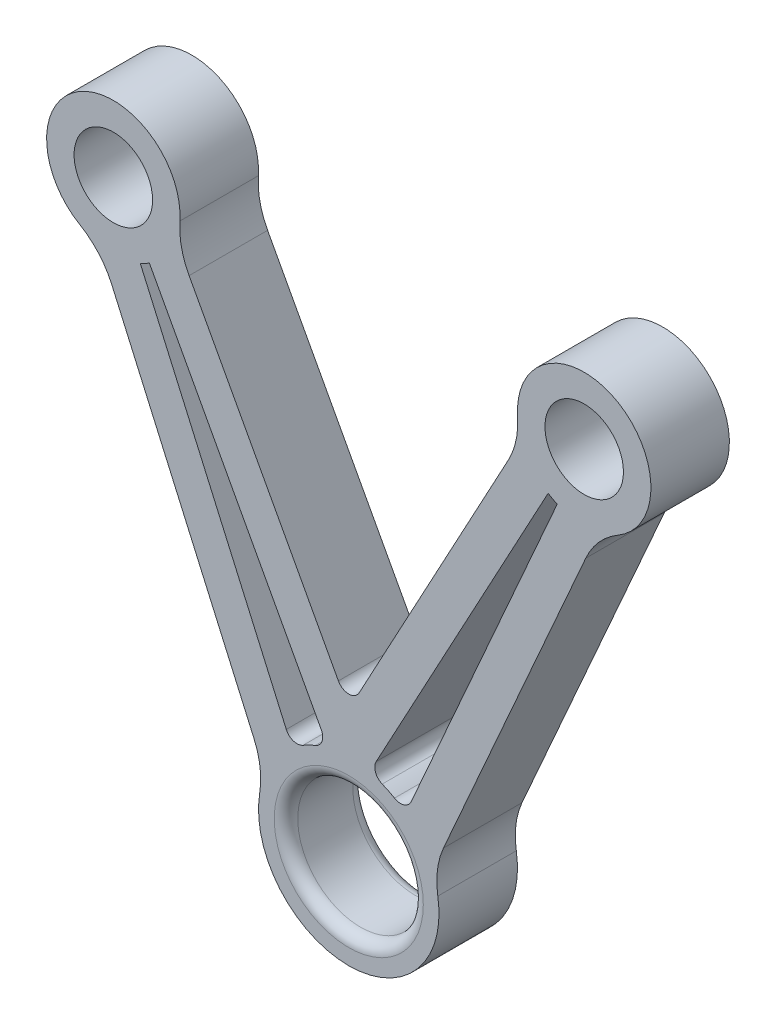
from build123d import *

# Parameters (mm, degrees)
SCHIZZO1_R                   = 5
SCHIZZO1_R_2                 = 8
ESTRUSIONE_ESTRUSIONE1_DEPTH = 5
RACCORDO1_R                  = 10
TAGLIO_ESTRUSIONE1_DEPTH     = 10
RACCORDO2_R                  = 1.5


with BuildPart() as part:
    # Schizzo1 → Estrusione-Estrusione1 (new body, symmetric)
    with BuildSketch(Plane.XY):
        with BuildLine():
            Line((-31.796659285, -8.307948929), (-10.655708964, -56.174972085))
            ThreePointArc((-10.655708964, -56.174972085), (0, -72), (10.655708964, -56.174972085))
            Line((10.655708964, -56.174972085), (31.796659285, -8.307948929))
            ThreePointArc((31.796659285, -8.307948929), (34.104135411, 7.443525544), (22.015418218, -2.914867709))
            Line((22.015418218, -2.914867709), (0, -43.668257767))
            Line((0, -43.668257767), (-22.015418218, -2.914867709))
            ThreePointArc((-22.015418218, -2.914867709), (-34.104135411, 7.443525544), (-31.796659285, -8.307948929))
        make_face()
        with Locations((-30, 0)):
            Circle(SCHIZZO1_R, mode=Mode.SUBTRACT)
        with Locations((30, 0)):
            Circle(SCHIZZO1_R, mode=Mode.SUBTRACT)
        with Locations((0, -60.5)):
            Circle(SCHIZZO1_R_2, mode=Mode.SUBTRACT)
    extrude(amount=ESTRUSIONE_ESTRUSIONE1_DEPTH, both=True)

    # Raccordo1
    raccordo1_edges = [part.edges().sort_by_distance(p)[0] for p in [
        (22.015418218, -2.914867709, 0),
        (31.796659285, -8.307948929, 0),
        (10.655708964, -56.174972085, 0),
        (-10.655708964, -56.174972085, 0),
        (-31.796659285, -8.307948929, 0),
        (-22.015418218, -2.914867709, 0),
    ]]
    fillet(raccordo1_edges, radius=RACCORDO1_R)

    # Schizzo2 → Taglio-Estrusione1 (cut)
    with BuildSketch(Plane.XY.offset(5)):
        with BuildLine():
            Line((-26.565911307, -7.775412198), (-7.229506839, -51.556609655))
            ThreePointArc((-7.229506839, -51.556609655), (-5.059978512, -50.173015084), (-2.637118885, -49.306448107))
            Line((-2.637118885, -49.306448107), (-25.408693659, -7.153314343))
            ThreePointArc((-25.408693659, -7.153314343), (-25.975264878, -7.486755452), (-26.565911307, -7.775412198))
        make_face()
        with BuildLine():
            Line((25.408693659, -7.153314343), (2.637118885, -49.306448107))
            ThreePointArc((2.637118885, -49.306448107), (5.059978512, -50.173015084), (7.229506839, -51.556609655))
            Line((7.229506839, -51.556609655), (26.565911307, -7.775412198))
            ThreePointArc((26.565911307, -7.775412198), (25.975264878, -7.486755452), (25.408693659, -7.153314343))
        make_face()
    extrude(amount=-TAGLIO_ESTRUSIONE1_DEPTH, mode=Mode.SUBTRACT)

    # Raccordo2
    raccordo2_edges = [part.edges().sort_by_distance(p)[0] for p in [
        (-8, -60.5, -5),
        (0, -43.668257767, 0),
        (-8, -60.5, 5),
        (7.229506839, -51.556609655, 0),
        (2.637118885, -49.306448107, 0),
        (-2.637118885, -49.306448107, 0),
        (-7.229506839, -51.556609655, 0),
    ]]
    fillet(raccordo2_edges, radius=RACCORDO2_R)


solid = part.part
